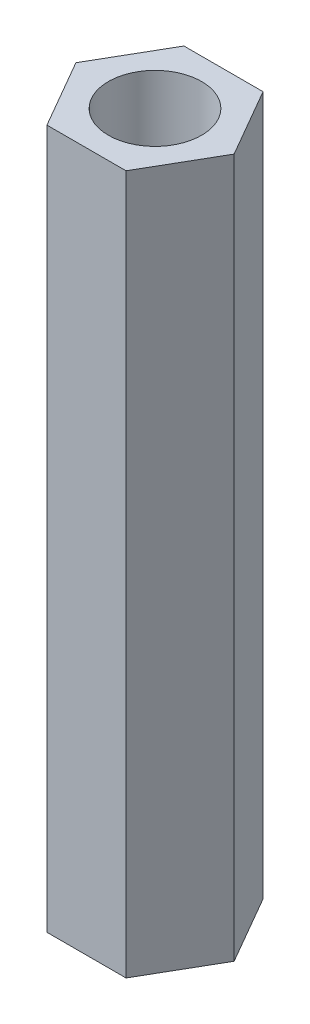
from build123d import *

# Parameters (mm, degrees)
SKETCH_1_R      = 1
EXTRUDE_1_DEPTH = 15


with BuildPart() as part:
    # 草图1 → 凸台-拉伸1 (new body)
    with BuildSketch(Plane(origin=(0, 0, 0), x_dir=(1, 0, 0), z_dir=(0, 1, 0))):
        Polygon((0.848704896, 1.47), (-0.848704896, 1.47), (-1.697409791, 0), (-0.848704896, -1.47), (0.848704896, -1.47), (1.697409791, 0), align=None)
        Circle(SKETCH_1_R, mode=Mode.SUBTRACT)
    extrude(amount=EXTRUDE_1_DEPTH)


solid = part.part
